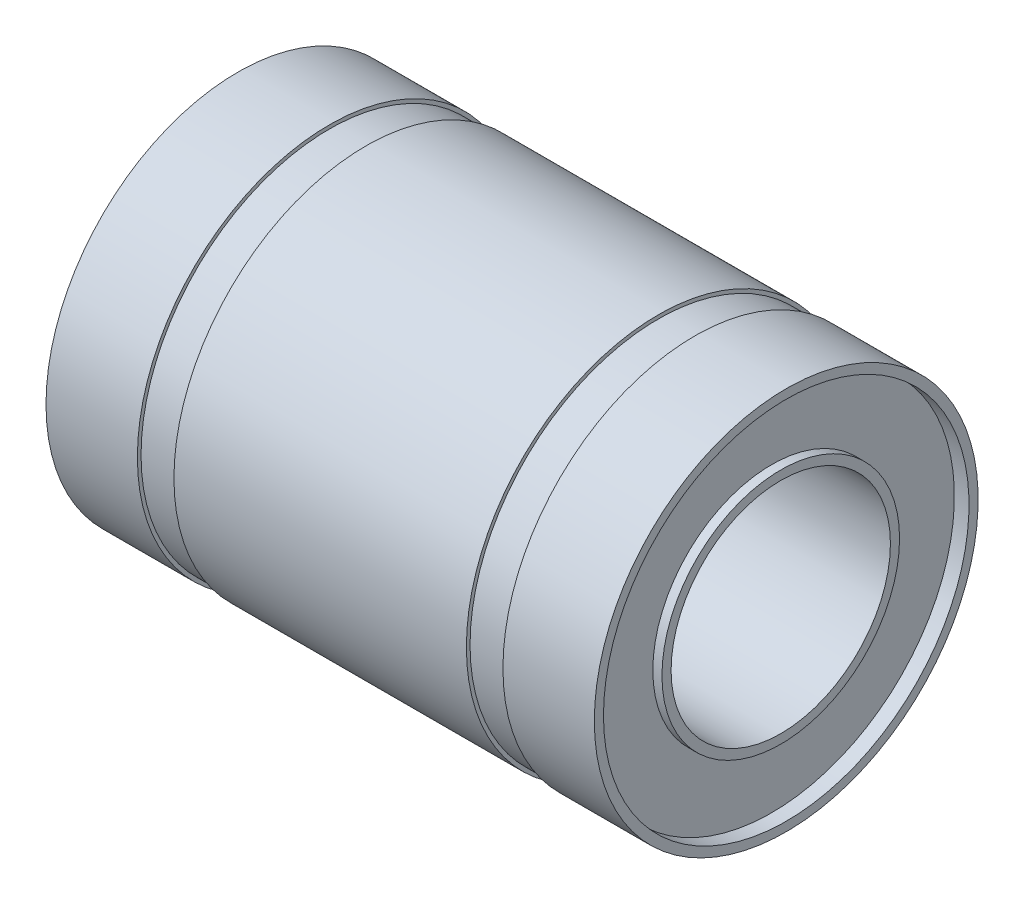
from build123d import *


with BuildPart() as part:
    # Sketch1 → Revolve1 (revolve)
    with BuildSketch(Plane.XY):
        Polygon((-8, 10.5), (8, 10.5), (8, 10.3), (10, 10.3), (10, 10.5), (15, 10.5), (15, 10), (14.2, 10), (14.2, 6.5), (14.7, 6.5), (14.7, 6), (-14.7, 6), (-14.7, 6.5), (-14.2, 6.5), (-14.2, 10), (-15, 10), (-15, 10.5), (-10, 10.5), (-10, 10.3), (-8, 10.3), align=None)
    revolve(axis=Axis((0, 0, 0), (1, 0, 0)))


solid = part.part
